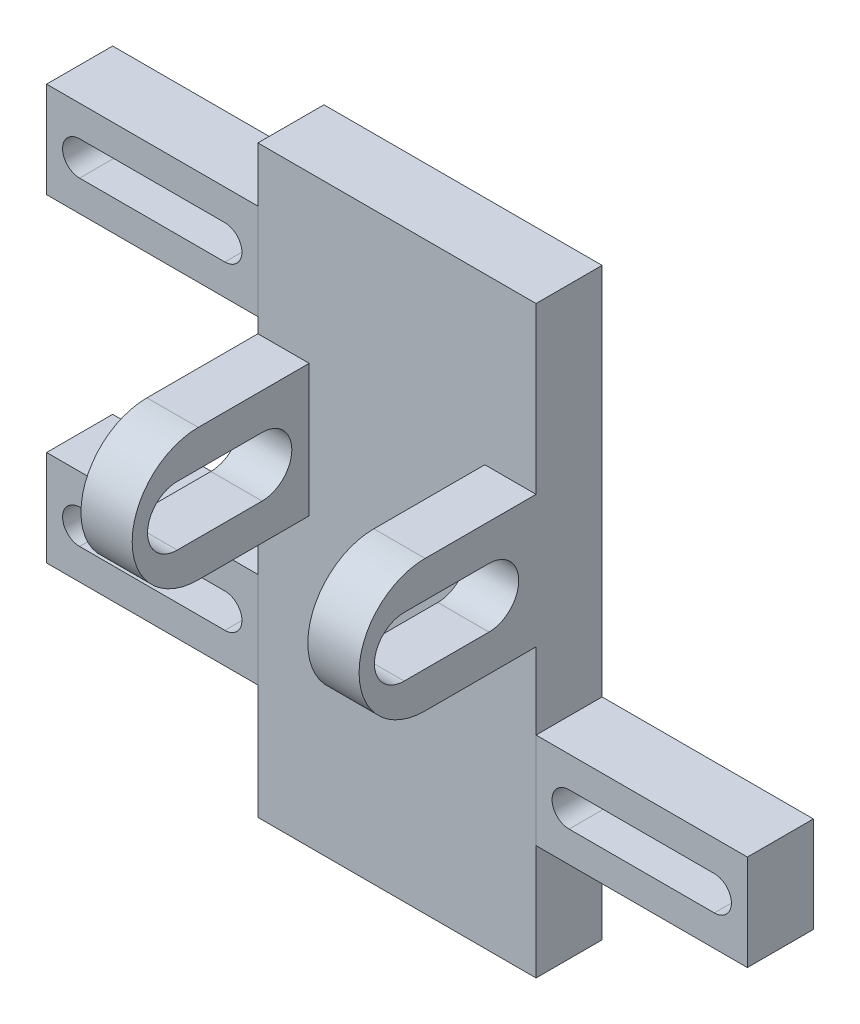
from build123d import *

# Parameters (mm, degrees)
SKETCH1_W           = 21.060518524
SKETCH1_H           = 44.229680595
BOSS_EXTRUDE1_DEPTH = 5
BOSS_EXTRUDE3_DEPTH = 3.8801
CUT_EXTRUDE1_DEPTH  = 8
SKETCH6_W           = 16
SKETCH6_H           = 7.25
BOSS_EXTRUDE4_DEPTH = 5
SKETCH11_W          = 16
SKETCH11_H          = 7.25
CUT_EXTRUDE2_DEPTH  = 5


with BuildPart() as part:
    # Sketch1 → Boss-Extrude1 (new body)
    with BuildSketch(Plane.XY):
        with Locations((4671.613089989, -40.729662913)):
            Rectangle(SKETCH1_W, SKETCH1_H)
    extrude(amount=BOSS_EXTRUDE1_DEPTH)

    # Sketch4 → Boss-Extrude3 (add)
    with BuildSketch(Plane.ZY.offset(-4661.082830727)):
        with BuildLine():
            Line((13.400549781, -31.129223835), (5, -31.129223835))
            Line((5, -31.129223835), (5, -41.129223835))
            Line((5, -41.129223835), (13.400549781, -41.129223835))
            ThreePointArc((13.400549781, -41.129223835), (18.400549781, -36.129223835), (13.400549781, -31.129223835))
        make_face()
    boss_extrude3 = extrude(amount=-BOSS_EXTRUDE3_DEPTH)

    # Sketch5 → Cut-Extrude1 (cut)
    with BuildSketch(Plane(origin=(4664.962930727, 0, 0), x_dir=(0, 0, -1), z_dir=(1, 0, 0))):
        with BuildLine():
            Line((-14.986353963, -33.879223835), (-8.563353453, -33.879223835))
            ThreePointArc((-8.563353453, -33.879223835), (-6.313353453, -36.129223835), (-8.563353453, -38.379223835))
            Line((-8.563353453, -38.379223835), (-14.986353963, -38.379223835))
            ThreePointArc((-14.986353963, -38.379223835), (-17.236353963, -36.129223835), (-14.986353963, -33.879223835))
        make_face()
    cut_extrude1 = extrude(amount=-CUT_EXTRUDE1_DEPTH, mode=Mode.SUBTRACT)

    # Mirror2: Boss-Extrude3, Cut-Extrude1 across plane
    add(boss_extrude3.mirror(Plane.ZY.offset(-4671.613089989)))
    add(cut_extrude1.mirror(Plane.ZY.offset(-4671.613089989)), mode=Mode.SUBTRACT)


with BuildPart() as body_2:
    # Sketch6 → Boss-Extrude4 (new body)
    with BuildSketch(Plane.XY.offset(5)):
        with Locations((4690.143349251, -50.538110101)):
            Rectangle(SKETCH6_W, SKETCH6_H)
        with BuildLine():
            Line((4695.643349251, -51.827953851), (4684.643349251, -51.827953851))
            ThreePointArc((4684.643349251, -51.827953851), (4683.353505501, -50.538110101), (4684.643349251, -49.248266351))
            Line((4684.643349251, -49.248266351), (4695.643349251, -49.248266351))
            ThreePointArc((4695.643349251, -49.248266351), (4696.933193001, -50.538110101), (4695.643349251, -51.827953851))
        make_face(mode=Mode.SUBTRACT)
    extrude(amount=-BOSS_EXTRUDE4_DEPTH)


with BuildPart() as body_3:
    # Mirror3: mirrored copy
    add(body_2.part.mirror(Plane.ZY.offset(-4671.613089989)))


with BuildPart() as body_4:
    # Mirror4: mirrored copy
    add(body_3.part.mirror(Plane(origin=(0, -38.461673776, 0), x_dir=(0, 0, 1), z_dir=(0, -1, 0))))


with BuildPart() as body_5:
    # Mirror4 2: mirrored copy
    add(body_2.part.mirror(Plane(origin=(0, -38.461673776, 0), x_dir=(0, 0, 1), z_dir=(0, -1, 0))))

    # Sketch11 → Cut-Extrude2 (cut)
    with BuildSketch(Plane.XY.offset(5)):
        with Locations((4690.143349251, -26.385237452)):
            Rectangle(SKETCH11_W, SKETCH11_H)
    extrude(amount=-CUT_EXTRUDE2_DEPTH, mode=Mode.SUBTRACT)


solid = Compound([part.part, body_2.part, body_3.part, body_4.part])
